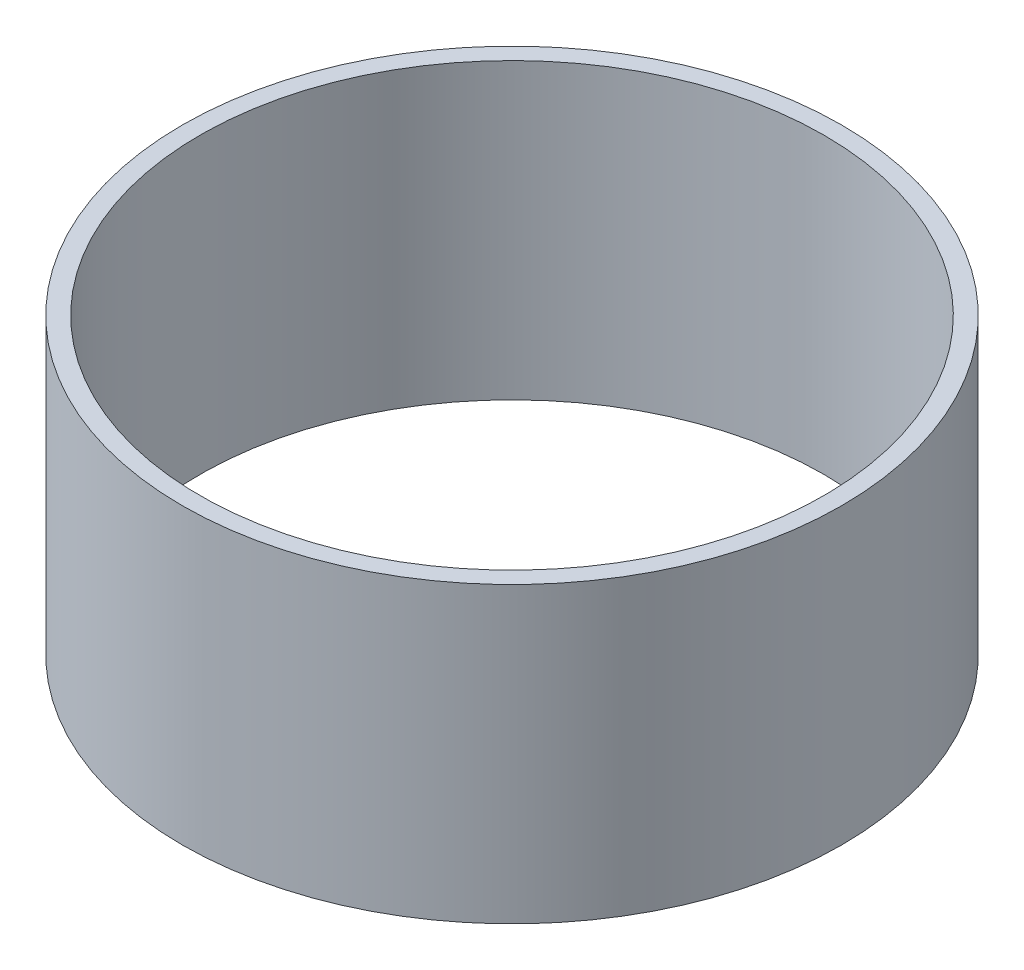
from build123d import *

# Parameters (mm, degrees)
SKETCH1_W = 1.524
SKETCH1_H = 25.4


with BuildPart() as part:
    # Sketch1 → Revolve1 (revolve)
    with BuildSketch(Plane.XY):
        with Locations((27.7368, 12.7)):
            Rectangle(SKETCH1_W, SKETCH1_H)
    revolve(axis=Axis((0, -13.97, 0), (0, 1, 0)))


solid = part.part
